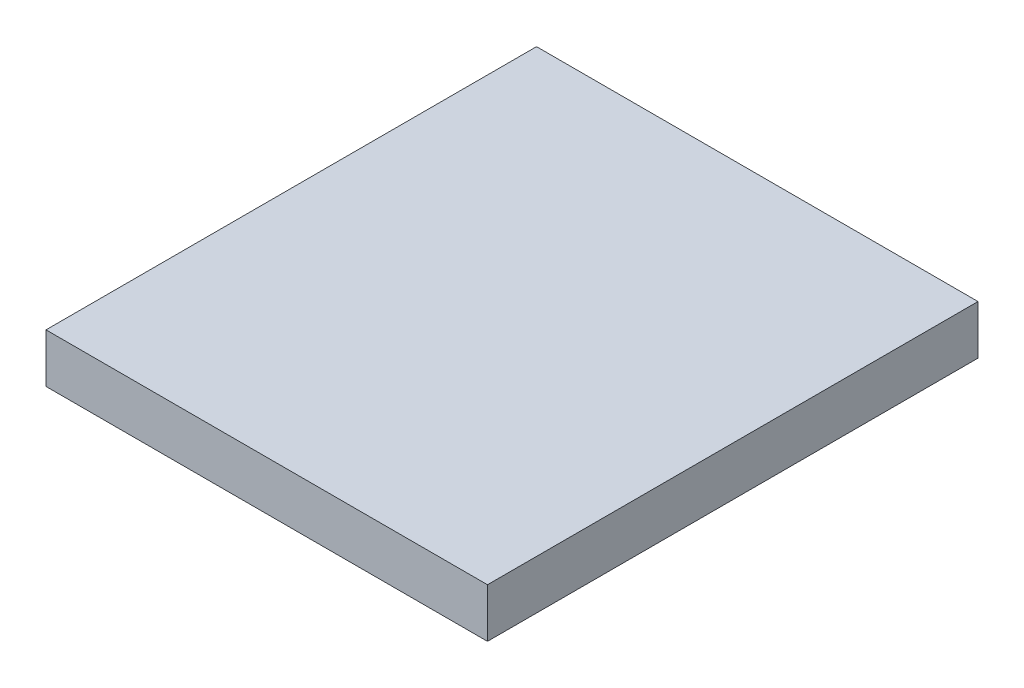
from build123d import *

# Parameters (mm, degrees)
SKETCH1_W           = 18
SKETCH1_H           = 20
BOSS_EXTRUDE1_DEPTH = 2


with BuildPart() as part:
    # Sketch1 → Boss-Extrude1 (new body)
    with BuildSketch(Plane(origin=(0, 0, 0), x_dir=(1, 0, 0), z_dir=(0, 1, 0))):
        Rectangle(SKETCH1_W, SKETCH1_H)
    extrude(amount=BOSS_EXTRUDE1_DEPTH)


solid = part.part
